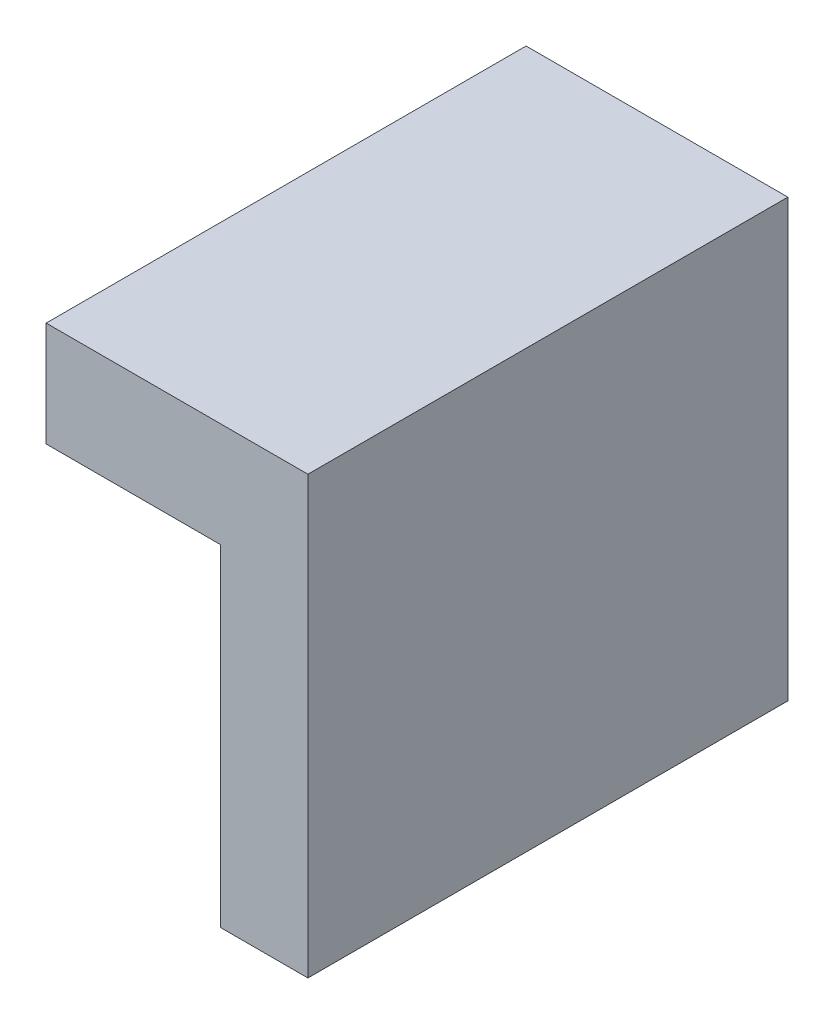
from build123d import *

# Parameters (mm, degrees)
BOSS_EXTRUDE1_DEPTH   = 55
BOSS_EXTRUDE1_2_DEPTH = 55
SKETCH2_W             = 4
SKETCH2_H             = 38
SKETCH2_W_2           = 6
BOSS_EXTRUDE2_DEPTH   = 5


with BuildPart() as part:
    # Sketch1 → Boss-Extrude1 (new body)
    with BuildSketch(Plane.XY):
        Polygon((9, 17), (-15, 17), (-15, 13), (5, 13), (5, -25), (9, -25), align=None)
    extrude(amount=BOSS_EXTRUDE1_DEPTH)



with BuildPart() as body_2:
    # Sketch1 → Boss-Extrude1 2 (new body)
    with BuildSketch(Plane.XY):
        Polygon((-15, 25), (-15, 20), (12, 20), (12, -25), (15, -25), (15, 25), align=None)
    extrude(amount=BOSS_EXTRUDE1_2_DEPTH)


with BuildPart() as part_1:
    add(part.part)

    add(body_2.part)  # Boss-Extrude2 merges body 2
    # Sketch2 → Boss-Extrude2 (add)
    with BuildSketch(Plane.XY.offset(55)):
        Polygon((-15, 25), (-15, 17), (9, 17), (9, 13), (15, 13), (15, 25), align=None)
        Polygon((-15, 17), (-15, 13), (5, 13), (9, 13), (9, 17), align=None)
        with Locations((7, -6)):
            Rectangle(SKETCH2_W, SKETCH2_H)
        with Locations((12, -6)):
            Rectangle(SKETCH2_W_2, SKETCH2_H)
    extrude(amount=-BOSS_EXTRUDE2_DEPTH)


solid = part_1.part
